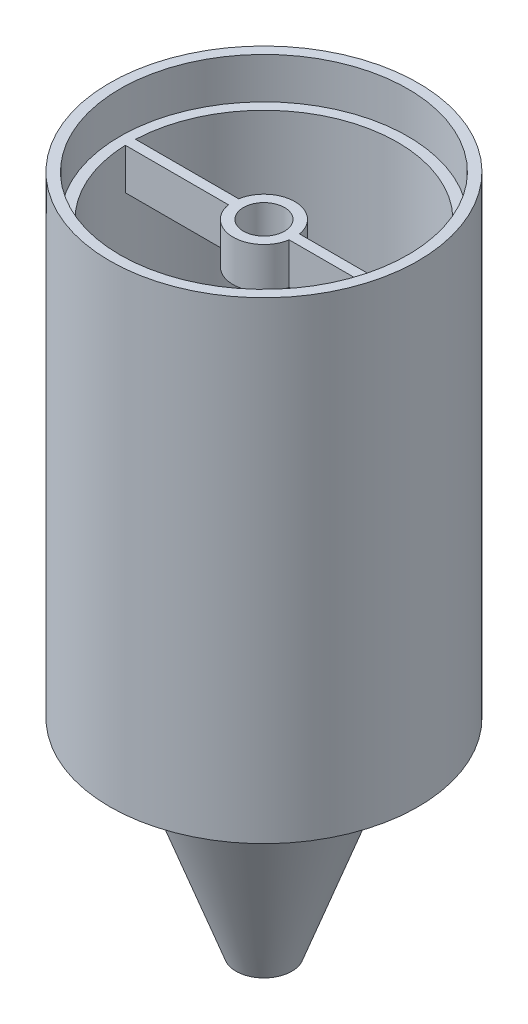
from build123d import *

# Parameters (mm, degrees)
SKETCH1_R           = 19.05
BOSS_EXTRUDE1_DEPTH = 2.54
SKETCH2_R           = 12.7
BOSS_EXTRUDE2_DEPTH = 25.4
BOSS_EXTRUDE2_TAPER = 20
SKETCH3_R           = 2.54
CUT_EXTRUDE1_DEPTH  = 27.94
CUT_EXTRUDE1_TAPER  = -20
SKETCH4_R           = 19.05
SKETCH4_R_2         = 16.51
BOSS_EXTRUDE3_DEPTH = 50.8
SKETCH5_R           = 19.05
SKETCH5_R_2         = 2.54
BOSS_EXTRUDE4_DEPTH = 5.08
SKETCH6_R           = 19.05
SKETCH6_R_2         = 17.78
BOSS_EXTRUDE5_DEPTH = 5.08


with BuildPart() as part:
    # Sketch1 → Boss-Extrude1 (new body)
    with BuildSketch(Plane(origin=(0, 0, 0), x_dir=(1, 0, 0), z_dir=(0, 1, 0))):
        Circle(SKETCH1_R)
    extrude(amount=BOSS_EXTRUDE1_DEPTH)

    # Sketch2 → Boss-Extrude2 (add)
    with BuildSketch(Plane.XZ):
        Circle(SKETCH2_R)
    extrude(amount=BOSS_EXTRUDE2_DEPTH, taper=BOSS_EXTRUDE2_TAPER)

    # Sketch3 → Cut-Extrude1 (cut)
    with BuildSketch(Plane.XZ.offset(25.4)):
        Circle(SKETCH3_R)
    extrude(amount=-CUT_EXTRUDE1_DEPTH, taper=CUT_EXTRUDE1_TAPER, mode=Mode.SUBTRACT)

    # Sketch4 → Boss-Extrude3 (add)
    with BuildSketch(Plane(origin=(0, 2.54, 0), x_dir=(1, 0, 0), z_dir=(0, 1, 0))):
        Circle(SKETCH4_R)
        Circle(SKETCH4_R_2, mode=Mode.SUBTRACT)
    extrude(amount=BOSS_EXTRUDE3_DEPTH)

    # Sketch5 → Boss-Extrude4 (add)
    with BuildSketch(Plane(origin=(0, 53.34, 0), x_dir=(1, 0, 0), z_dir=(0, 1, 0))):
        Circle(SKETCH5_R)
        Circle(SKETCH5_R_2, mode=Mode.SUBTRACT)
        with BuildLine():
            Line((3.756710662, 0.635), (16.497783942, 0.635))
            ThreePointArc((16.497783942, 0.635), (0, 16.51), (-16.497783942, 0.635))
            Line((-16.497783942, 0.635), (-3.756710662, 0.635))
            ThreePointArc((-3.756710662, 0.635), (0, 3.81), (3.756710662, 0.635))
        make_face(mode=Mode.SUBTRACT)
        with BuildLine():
            Line((3.756710662, -0.635), (16.497783942, -0.635))
            ThreePointArc((16.497783942, -0.635), (0, -16.51), (-16.497783942, -0.635))
            Line((-16.497783942, -0.635), (-3.756710662, -0.635))
            ThreePointArc((-3.756710662, -0.635), (0, -3.81), (3.756710662, -0.635))
        make_face(mode=Mode.SUBTRACT)
    extrude(amount=-BOSS_EXTRUDE4_DEPTH)

    # Sketch6 → Boss-Extrude5 (add)
    with BuildSketch(Plane(origin=(0, 53.34, 0), x_dir=(1, 0, 0), z_dir=(0, 1, 0))):
        Circle(SKETCH6_R)
        Circle(SKETCH6_R_2, mode=Mode.SUBTRACT)
    extrude(amount=BOSS_EXTRUDE5_DEPTH)


solid = part.part
